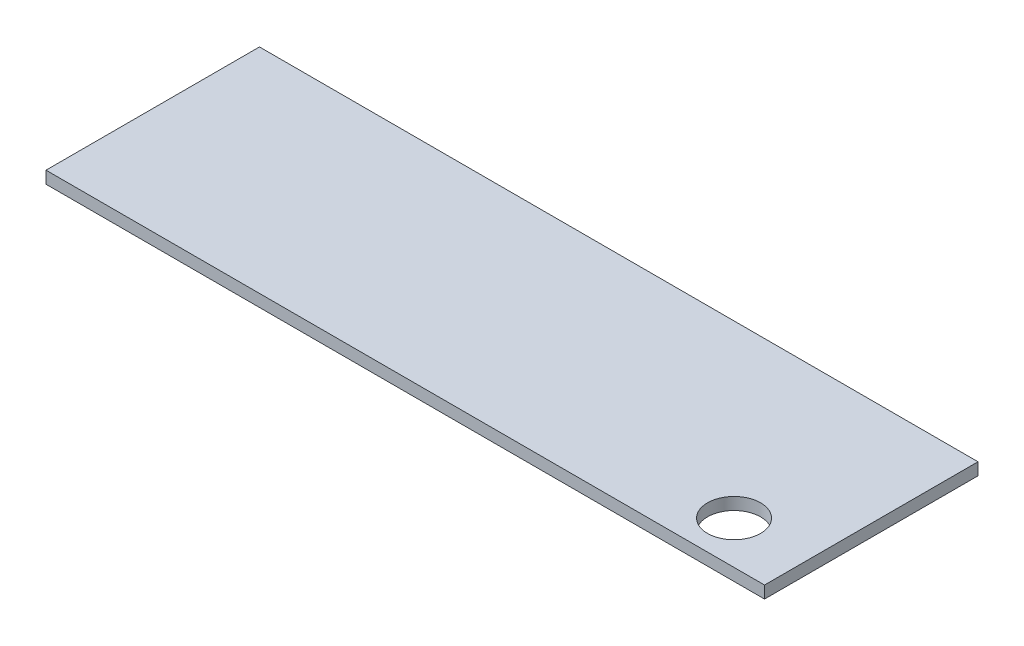
from build123d import *

# Parameters (mm, degrees)
SKETCH1_W           = 117.809724509
SKETCH1_H           = 35
SKETCH1_R           = 4.35
BOSS_EXTRUDE1_DEPTH = 2


with BuildPart() as part:
    # Sketch1 → Boss-Extrude1 (new body)
    with BuildSketch(Plane(origin=(0, 0, 0), x_dir=(1, 0, 0), z_dir=(0, 1, 0))):
        with Locations((-41.117713661, 17.5)):
            Rectangle(SKETCH1_W, SKETCH1_H)
        with Locations((5.787148594, 7)):
            Circle(SKETCH1_R, mode=Mode.SUBTRACT)
    extrude(amount=BOSS_EXTRUDE1_DEPTH)


solid = part.part
